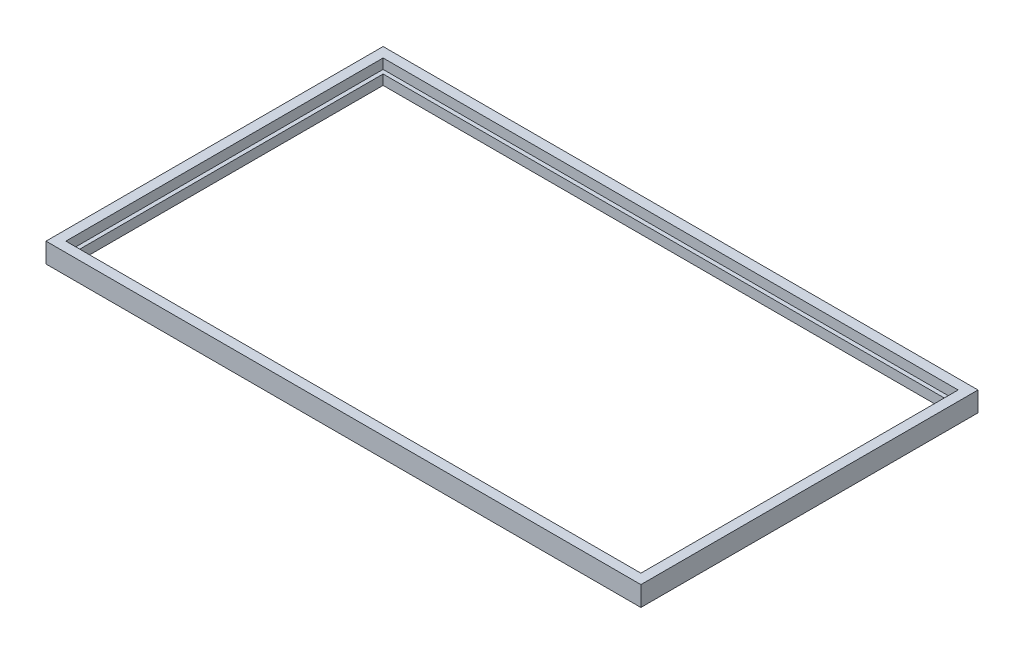
from build123d import *

# Parameters (mm, degrees)
SKETCH1_W               = 300
SKETCH1_H               = 170
BOSS_EXTRUDE1_DEPTH     = 10
SKETCH2_W               = 290
SKETCH2_H               = 160
SKETCH2_W_2             = 286
SKETCH2_H_2             = 156
CUT_EXTRUDE1_DEPTH      = 5
SKETCH5_W               = 286
SKETCH5_H               = 156
CUT_EXTRUDE2_DEPTH      = 28
CUT_EXTRUDE2_DEPTH_BACK = 40


with BuildPart() as part:
    # Sketch1 → Boss-Extrude1 (new body)
    with BuildSketch(Plane(origin=(0, 0, 0), x_dir=(1, 0, 0), z_dir=(0, 1, 0))):
        with Locations((-10.575275385, -12.987279515)):
            Rectangle(SKETCH1_W, SKETCH1_H)
    extrude(amount=BOSS_EXTRUDE1_DEPTH)

    # Sketch2 → Cut-Extrude1 (cut)
    with BuildSketch(Plane(origin=(0, 10, 0), x_dir=(1, 0, 0), z_dir=(0, 1, 0))):
        with Locations((-10.575275385, -12.987279515)):
            Rectangle(SKETCH2_W, SKETCH2_H)
        with Locations((-10.575275385, -12.987279515)):
            Rectangle(SKETCH2_W_2, SKETCH2_H_2, mode=Mode.SUBTRACT)
    extrude(amount=-CUT_EXTRUDE1_DEPTH, mode=Mode.SUBTRACT)

    # Sketch5 → Cut-Extrude2 (cut, two sides)
    with BuildSketch(Plane(origin=(0, 10, 0), x_dir=(1, 0, 0), z_dir=(0, 1, 0))) as cut_extrude2_sk:
        with Locations((-10.575275385, -12.987279515)):
            Rectangle(SKETCH5_W, SKETCH5_H)
    extrude(amount=CUT_EXTRUDE2_DEPTH, mode=Mode.SUBTRACT)
    extrude(cut_extrude2_sk.sketch, amount=-CUT_EXTRUDE2_DEPTH_BACK, mode=Mode.SUBTRACT)


solid = part.part
